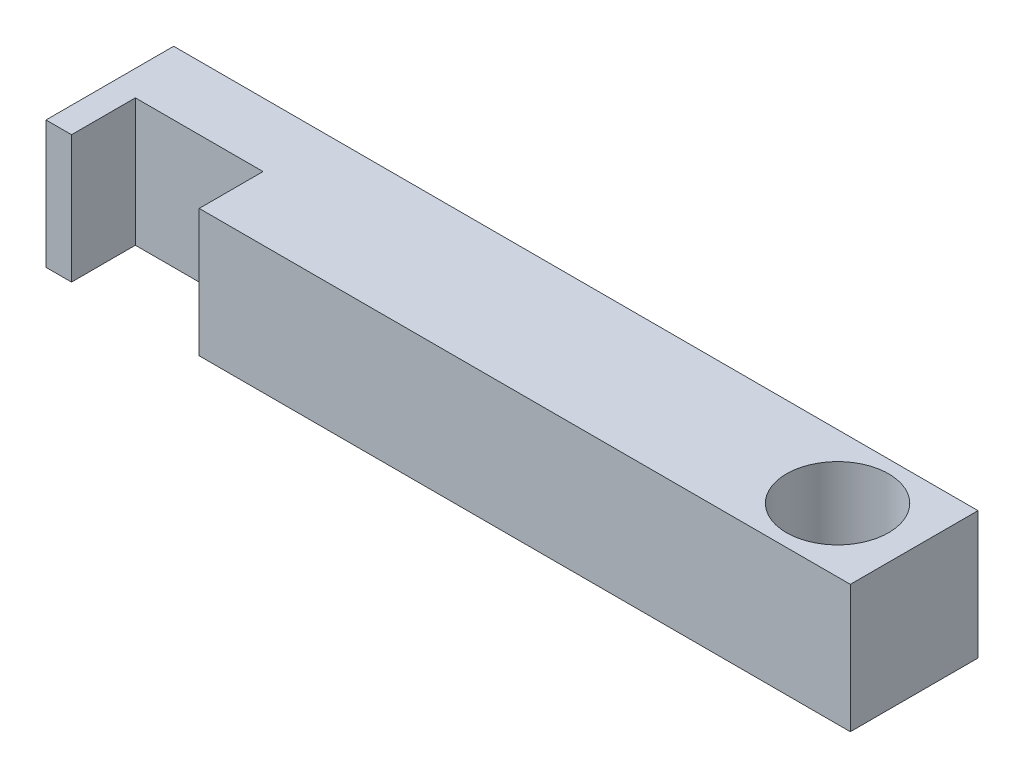
from build123d import *

# Parameters (mm, degrees)
SKETCH_1_R      = 4
EXTRUDE_1_DEPTH = 5


with BuildPart() as part:
    # 草圖1 → 填料-伸長1 (new body, symmetric)
    with BuildSketch(Plane(origin=(0, 0, 0), x_dir=(1, 0, 0), z_dir=(0, 1, 0))):
        Polygon((-55, -5), (-55, 0), (-45, 0), (-45, -5), (6, -5), (6, 5), (-57, 5), (-57, -5), align=None)
        Circle(SKETCH_1_R, mode=Mode.SUBTRACT)
    extrude(amount=EXTRUDE_1_DEPTH, both=True)


solid = part.part
